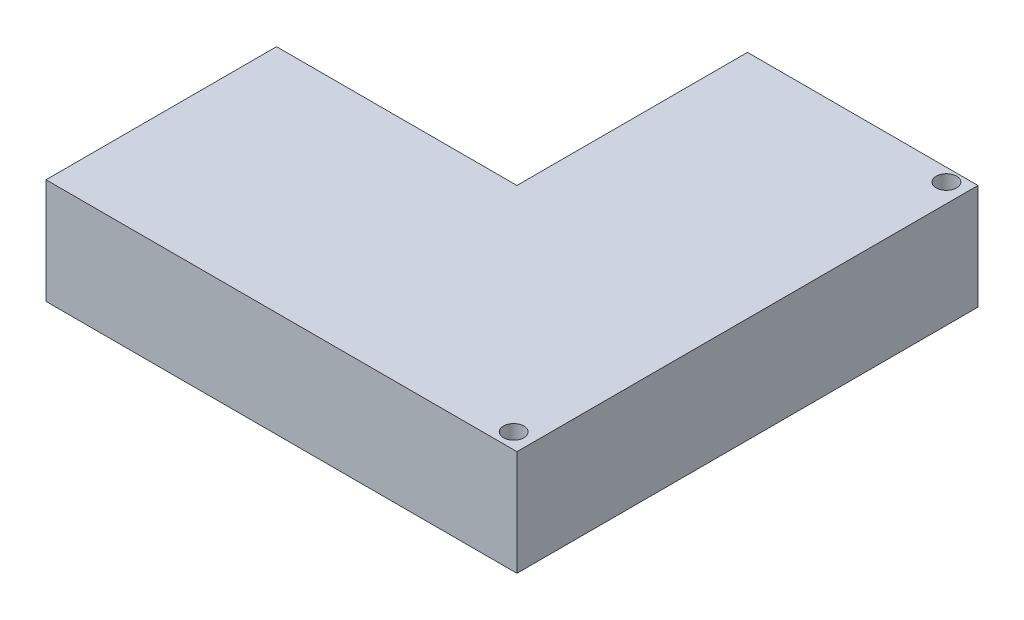
from build123d import *

# Parameters (mm, degrees)
BOSS_EXTRUDE1_DEPTH = 8
MOVE_FACE1_BY       = 19
SKETCH3_R           = 1.55
CUT_EXTRUDE1_DEPTH  = 99.460415825


with BuildPart() as part:
    # Sketch2 → Boss-Extrude1 (new, symmetric)
    with BuildSketch(Plane.XZ):
        Polygon((-13.796187154, 46.508213699), (-13.796187154, -23.491786301), (-48.796187154, -23.491786301), (-48.796187154, 11.508213699), (-104.296187154, 11.508213699), (-104.296187154, 46.508213699), align=None)
    extrude(amount=BOSS_EXTRUDE1_DEPTH, both=True)

    # Move Face1: a face moved inward by 19.0
    extrude(part.faces().sort_by_distance((-104.296187154, 0, 29.008213699))[0], amount=MOVE_FACE1_BY, dir=(1, 0, 0), mode=Mode.SUBTRACT)

    # Sketch3 → Cut-Extrude1 (cut, through all)
    with BuildSketch(Plane.XZ.offset(8)):
        with Locations(Location((-16.646187154, 44.158213699, 0), (0, 0, 270))):
            Circle(SKETCH3_R)
        with Locations(Location((-16.646187154, -21.541786301, 0), (0, 0, 270))):
            Circle(SKETCH3_R)
    extrude(amount=-CUT_EXTRUDE1_DEPTH, mode=Mode.SUBTRACT)


solid = part.part
